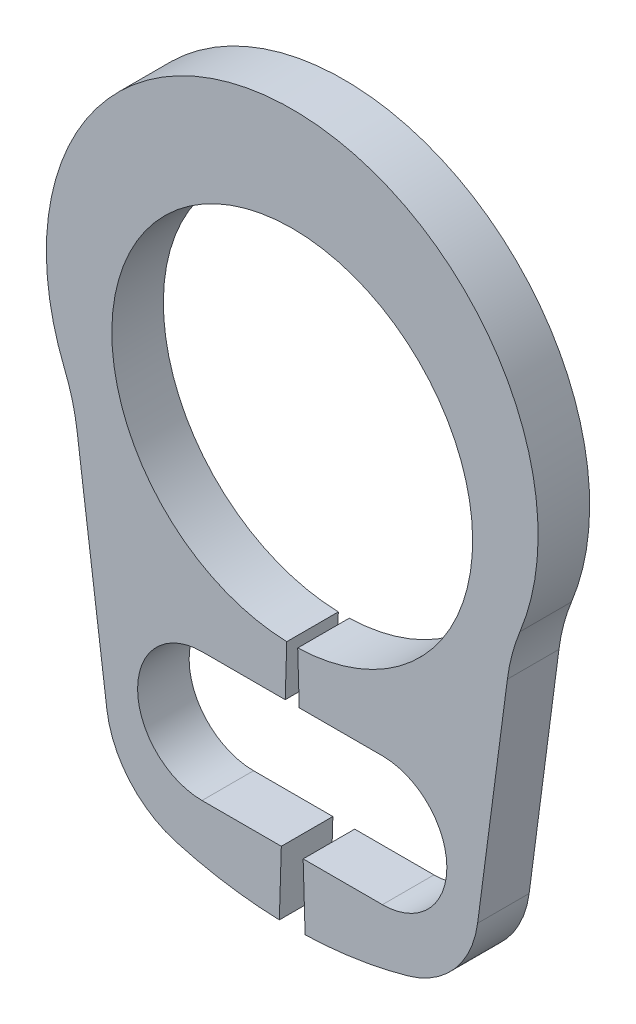
from build123d import *

# Parameters (mm, degrees)
BODYSKE_R   = 0.5
BODY_DEPTH  = 0.4
NOTSKE_W    = 1.4
NOTSKE_H    = 1
NOTCH_DEPTH = 1.4


with BuildPart() as part:
    # BodySke → Body (new body)
    with BuildSketch(Plane.XY):
        with BuildLine():
            Line((0.042424242, -1.399357061), (0.1, -3.2984845))
            ThreePointArc((0.1, -3.2984845), (0.503496069, -3.261363474), (0.899400996, -3.175071314))
            ThreePointArc((0.899400996, -3.175071314), (1.26237777, -2.943946636), (1.438575325, -2.551358841))
            Line((1.438575325, -2.551358841), (1.669747251, -0.795433731))
            ThreePointArc((1.669747251, -0.795433731), (1.706652618, -0.608442547), (1.767111235, -0.427687286))
            ThreePointArc((1.767111235, -0.427687286), (0, 2.2), (-1.767111235, -0.427687286))
            ThreePointArc((-1.767111235, -0.427687286), (-1.706652618, -0.608442547), (-1.669747251, -0.795433731))
            Line((-1.669747251, -0.795433731), (-1.438575325, -2.551358841))
            ThreePointArc((-1.438575325, -2.551358841), (-1.26237777, -2.943946636), (-0.899400996, -3.175071314))
            ThreePointArc((-0.899400996, -3.175071314), (-0.503496069, -3.261363474), (-0.1, -3.2984845))
            Line((-0.1, -3.2984845), (-0.042424242, -1.399357061))
            ThreePointArc((-0.042424242, -1.399357061), (0, 1.4), (0.042424242, -1.399357061))
        make_face()
        with Locations((0.7, -2.295648057)):
            Circle(BODYSKE_R, mode=Mode.SUBTRACT)
        with Locations((-0.7, -2.295648057)):
            Circle(BODYSKE_R, mode=Mode.SUBTRACT)
    extrude(amount=-BODY_DEPTH)

    # NotSke → Notch (cut, through all)
    with BuildSketch(Plane.XY):
        with Locations((0, -2.295648057)):
            Rectangle(NOTSKE_W, NOTSKE_H)
    extrude(amount=-NOTCH_DEPTH, mode=Mode.SUBTRACT)


solid = part.part
